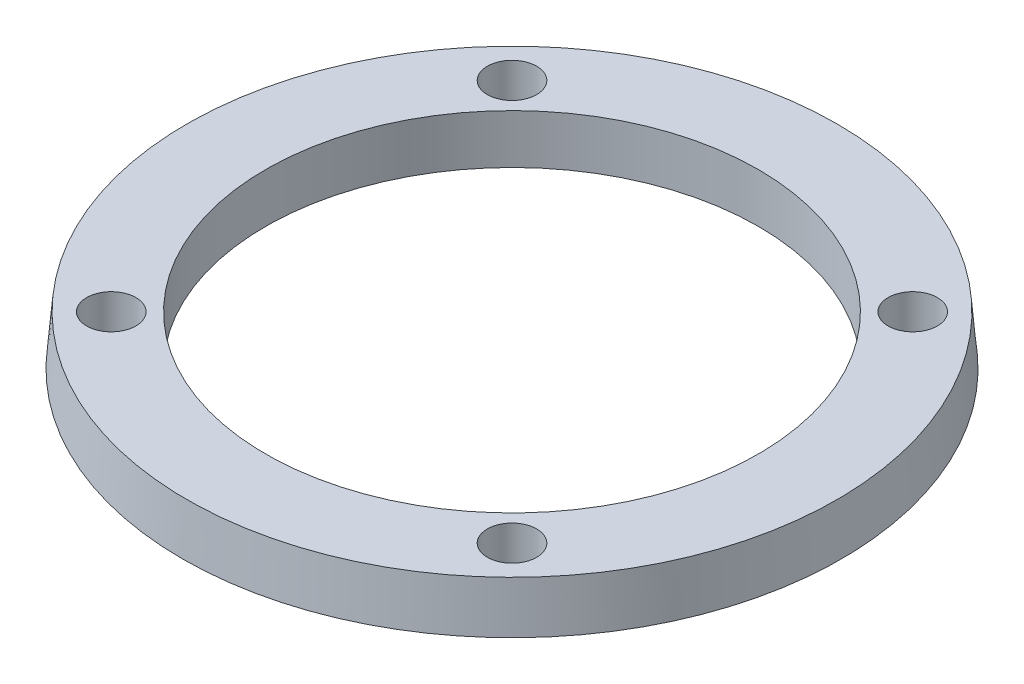
from build123d import *

# Parameters (mm, degrees)
SKETCH3_R          = 2
CUT_EXTRUDE1_DEPTH = 5


with BuildPart() as part:
    # Sketch1 → Revolve1 (revolve)
    with BuildSketch(Plane.XY):
        Polygon((-26.75, 0), (-26.400045346, 4), (-20, 4), (-20, 0), align=None)
    revolve(axis=Axis((0, 0, 0), (0, 1, 0)))

    # Sketch3 → Cut-Extrude1 (cut, through all)
    with BuildSketch(Plane.XZ):
        with Locations((-16.263455967, 16.263455967)):
            Circle(SKETCH3_R)
        with Locations((16.263455967, 16.263455967)):
            Circle(SKETCH3_R)
        with Locations((-16.263455967, -16.263455967)):
            Circle(SKETCH3_R)
        with Locations((16.263455967, -16.263455967)):
            Circle(SKETCH3_R)
    extrude(amount=-CUT_EXTRUDE1_DEPTH, mode=Mode.SUBTRACT)


solid = part.part
